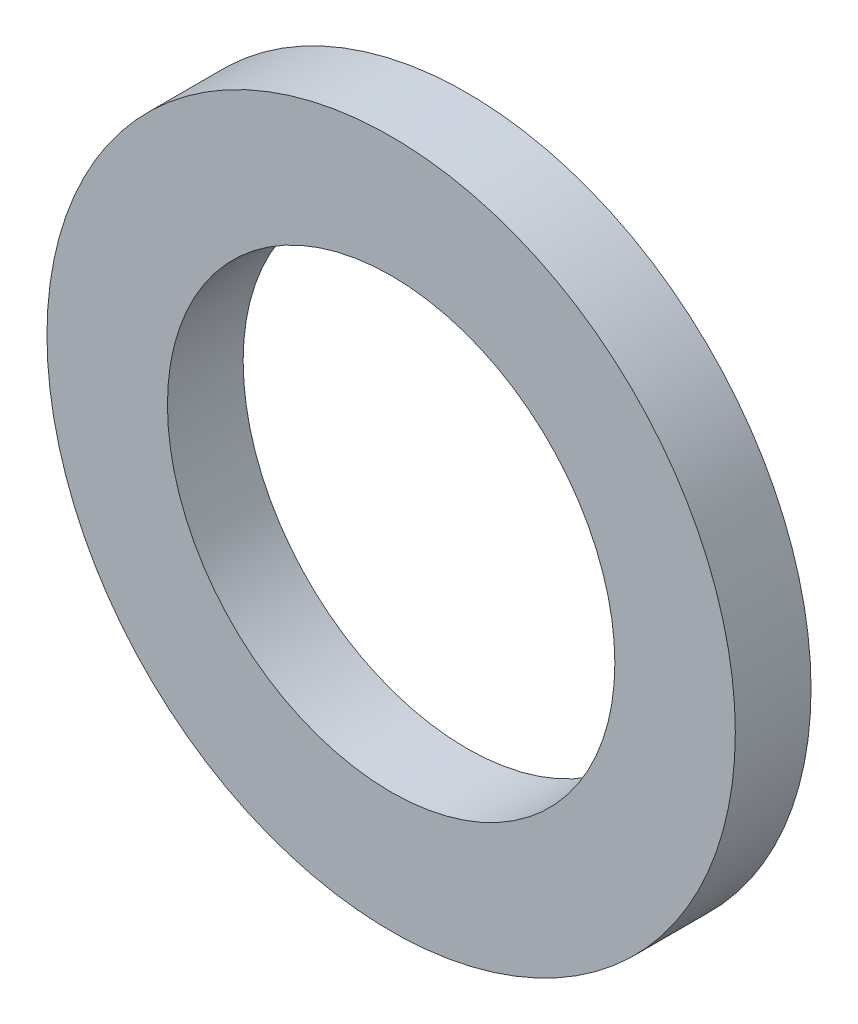
from build123d import *

# Parameters (mm, degrees)
SKIZZE1_R                       = 10
SKIZZE1_R_2                     = 6.5
AUFSATZ_LINEAR_AUSTRAGEN1_DEPTH = 2.2


with BuildPart() as part:
    # Skizze1 → Aufsatz-Linear austragen1 (new body)
    with BuildSketch(Plane.XY):
        Circle(SKIZZE1_R)
        Circle(SKIZZE1_R_2, mode=Mode.SUBTRACT)
    extrude(amount=AUFSATZ_LINEAR_AUSTRAGEN1_DEPTH)


solid = part.part
